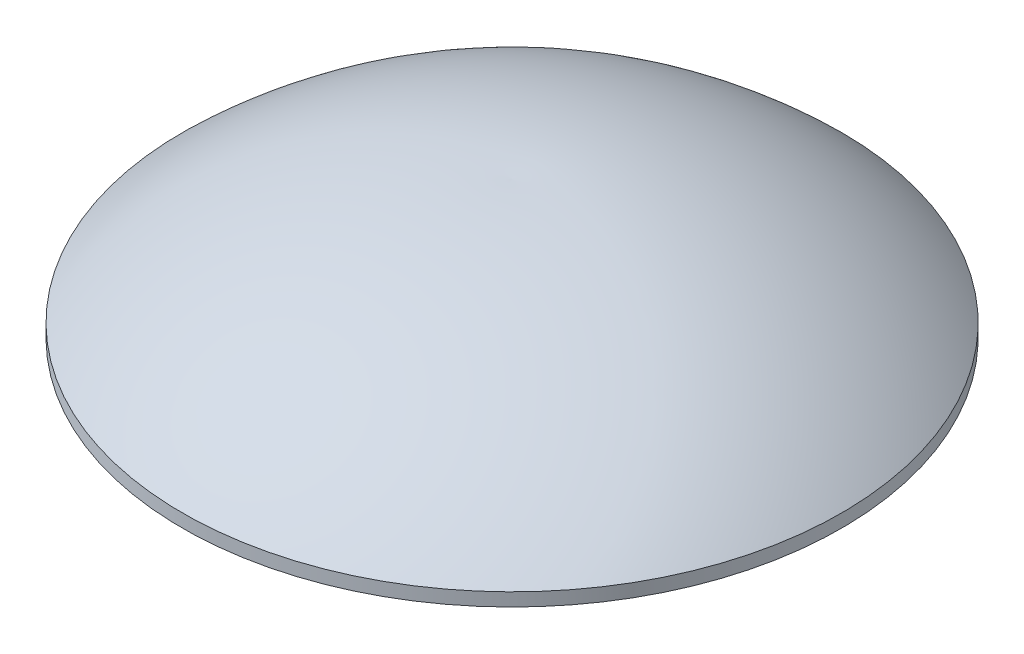
from build123d import *


with BuildPart() as part:
    # Sketch1 → Revolve1 (revolve)
    with BuildSketch(Plane.XY):
        with BuildLine():
            Line((-2.5, 0.1), (-2.5, 0))
            Line((-2.5, 0), (0, 0))
            Line((0, 0), (0, 1.046517266))
            ThreePointArc((0, 1.046517266), (-1.345462348, 0.825399698), (-2.5, 0.1))
        make_face()
    revolve(axis=Axis((0, -0.535647926, 0), (0, 1, 0)))


solid = part.part
